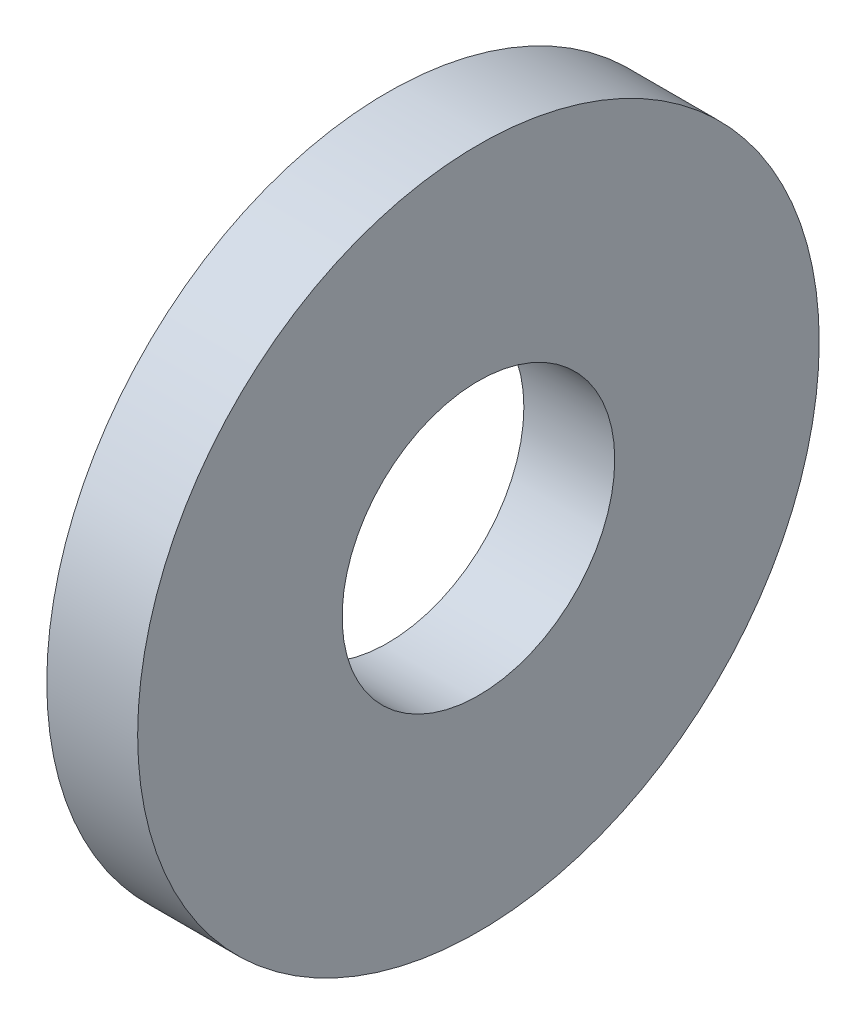
from build123d import *

# Parameters (mm, degrees)
SKETCH1_R               = 7.5
BOSS_EXTRUDE1_DEPTH     = 2
SKETCH2_R               = 3
CUT_EXTRUDE1_DEPTH      = 1
CUT_EXTRUDE1_DEPTH_BACK = 3


with BuildPart() as part:
    # Sketch1 → Boss-Extrude1 (new body)
    with BuildSketch(Plane(origin=(0, 0, 0), x_dir=(0, 0, -1), z_dir=(1, 0, 0))):
        Circle(SKETCH1_R)
    extrude(amount=BOSS_EXTRUDE1_DEPTH)

    # Sketch2 → Cut-Extrude1 (cut, two sides)
    with BuildSketch(Plane(origin=(2, 0, 0), x_dir=(0, 0, -1), z_dir=(1, 0, 0))) as cut_extrude1_sk:
        Circle(SKETCH2_R)
    extrude(amount=CUT_EXTRUDE1_DEPTH, mode=Mode.SUBTRACT)
    extrude(cut_extrude1_sk.sketch, amount=-CUT_EXTRUDE1_DEPTH_BACK, mode=Mode.SUBTRACT)


solid = part.part
